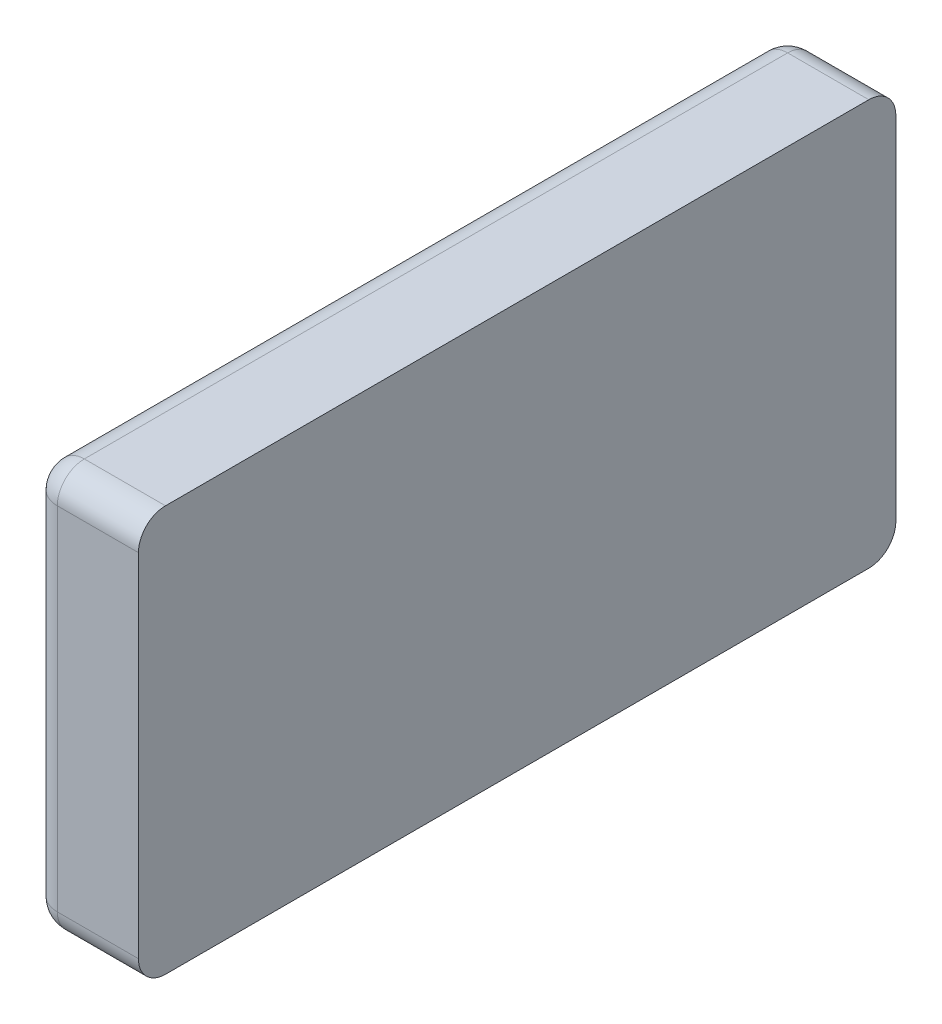
from build123d import *

# Parameters (mm, degrees)
DODANIE_WYCI_GNI_CIE1_DEPTH = 40
ZAOKR_GLENIE1_R             = 10


with BuildPart() as part:
    # Szkic1 → Dodanie-wyciągnięcie1 (new body)
    with BuildSketch(Plane.ZY.offset(-1032.6)):
        with BuildLine():
            Line((622.51, 65), (622.51, -65))
            ThreePointArc((622.51, -65), (625.438932188, -72.071067812), (632.51, -75))
            Line((632.51, -75), (892.51, -75))
            ThreePointArc((892.51, -75), (899.581067812, -72.071067812), (902.51, -65))
            Line((902.51, -65), (902.51, 65))
            ThreePointArc((902.51, 65), (899.581067812, 72.071067812), (892.51, 75))
            Line((892.51, 75), (632.51, 75))
            ThreePointArc((632.51, 75), (625.438932188, 72.071067812), (622.51, 65))
        make_face()
    extrude(amount=DODANIE_WYCI_GNI_CIE1_DEPTH)

    # Zaokrąglenie1
    zaokr_glenie1_edges = [part.edges().sort_by_distance(p)[0] for p in [
        (992.6, -72.071067812, 625.438932188),
        (992.6, -75, 762.51),
        (992.6, -72.071067812, 899.581067812),
        (992.6, 0, 902.51),
        (992.6, 72.071067812, 899.581067812),
        (992.6, 75, 762.51),
        (992.6, 72.071067812, 625.438932188),
        (992.6, 0, 622.51),
    ]]
    fillet(zaokr_glenie1_edges, radius=ZAOKR_GLENIE1_R)


solid = part.part
